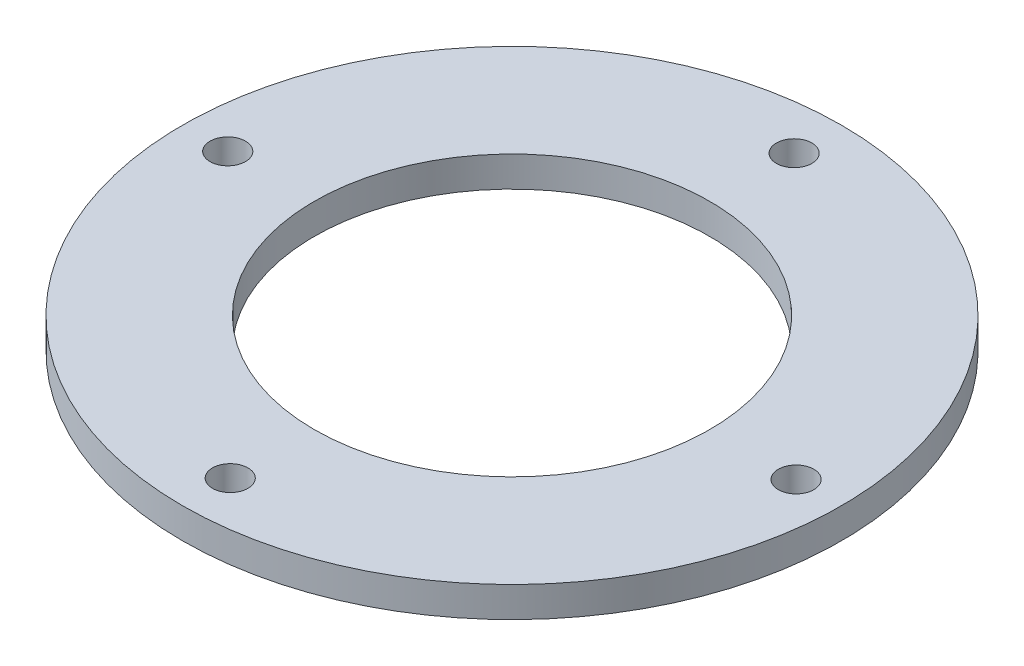
from build123d import *

# Parameters (mm, degrees)
SKETCH1_R                = 32.5
SKETCH1_R_2              = 19.5
BOSS_EXTRUDE2_DEPTH      = 3
SKETCH2_R                = 1.75
CUT_EXTRUDE2_DEPTH       = 1
CUT_EXTRUDE2_DEPTH_BACK  = 4
SKETCH5_R                = 1.75
CUT_EXTRUDE4_DEPTH       = 1
CUT_EXTRUDE4_DEPTH_BACK  = 4
SKETCH13_R               = 1.75
CUT_EXTRUDE12_DEPTH      = 1
CUT_EXTRUDE12_DEPTH_BACK = 4


with BuildPart() as part:
    # Sketch1 → Boss-Extrude2 (new body)
    with BuildSketch(Plane(origin=(0, 0, 0), x_dir=(1, 0, 0), z_dir=(0, 1, 0))):
        Circle(SKETCH1_R)
        Circle(SKETCH1_R_2, mode=Mode.SUBTRACT)
    extrude(amount=BOSS_EXTRUDE2_DEPTH)

    # Sketch2 → Cut-Extrude2 (cut, two sides)
    with BuildSketch(Plane(origin=(0, 3, 0), x_dir=(1, 0, 0), z_dir=(0, 1, 0))) as cut_extrude2_sk:
        with Locations((0, -27.788884535)):
            Circle(SKETCH2_R)
    extrude(amount=CUT_EXTRUDE2_DEPTH, mode=Mode.SUBTRACT)
    extrude(cut_extrude2_sk.sketch, amount=-CUT_EXTRUDE2_DEPTH_BACK, mode=Mode.SUBTRACT)

    # Sketch5 → Cut-Extrude4 (cut, two sides)
    with BuildSketch(Plane(origin=(0, 3, 0), x_dir=(1, 0, 0), z_dir=(0, 1, 0))) as cut_extrude4_sk:
        with Locations((0.057759675, 27.766269398)):
            Circle(SKETCH5_R)
    extrude(amount=CUT_EXTRUDE4_DEPTH, mode=Mode.SUBTRACT)
    extrude(cut_extrude4_sk.sketch, amount=-CUT_EXTRUDE4_DEPTH_BACK, mode=Mode.SUBTRACT)

    # Sketch13 → Cut-Extrude12 (cut, two sides)
    with BuildSketch(Plane(origin=(0, 3, 0), x_dir=(1, 0, 0), z_dir=(0, 1, 0))) as cut_extrude12_sk:
        with Locations((-28.027387252, -0.003979104)):
            Circle(SKETCH13_R)
        with Locations((28.01619309, 0)):
            Circle(SKETCH13_R)
    extrude(amount=CUT_EXTRUDE12_DEPTH, mode=Mode.SUBTRACT)
    extrude(cut_extrude12_sk.sketch, amount=-CUT_EXTRUDE12_DEPTH_BACK, mode=Mode.SUBTRACT)


solid = part.part
